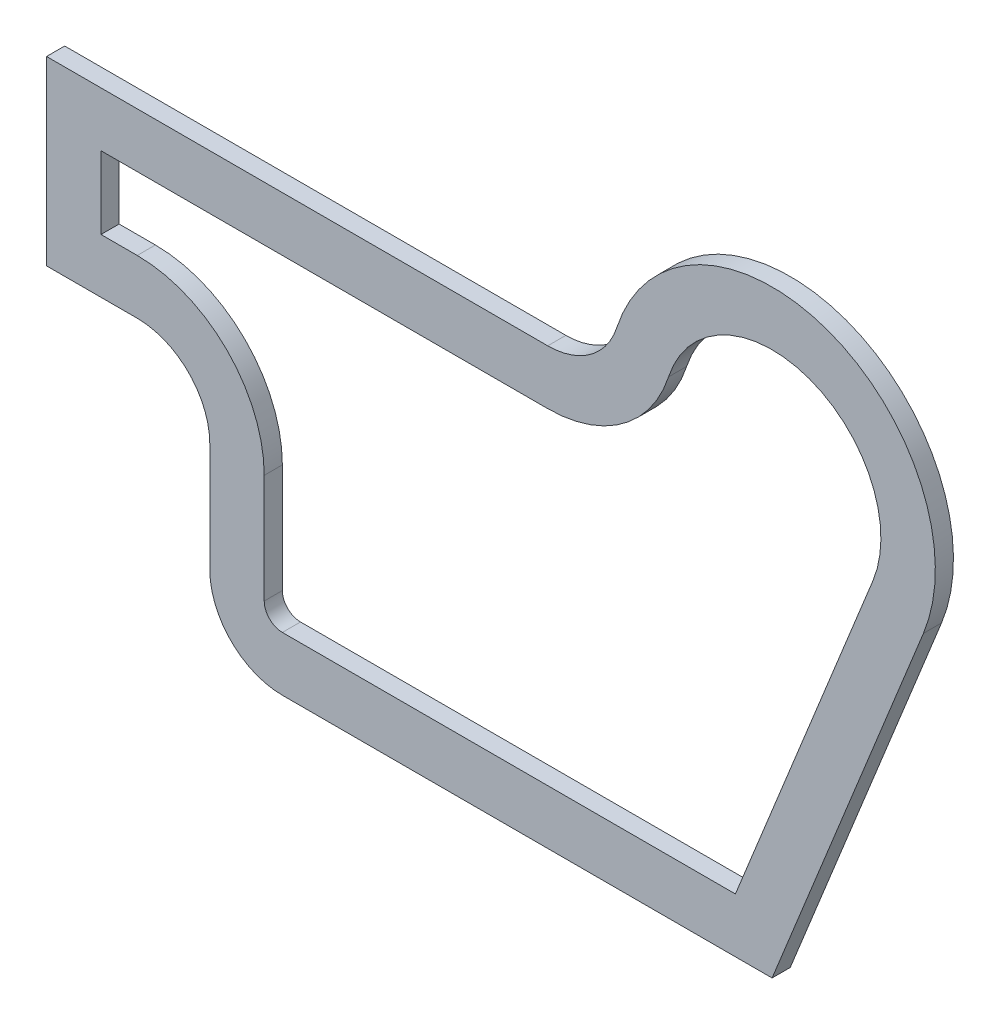
from build123d import *

# Parameters (mm, degrees)
SKETCH1_R           = 20
BOSS_EXTRUDE1_DEPTH = 5
CUT_EXTRUDE1_DEPTH  = 6


with BuildPart() as part:
    # Sketch1 → Boss-Extrude1 (new body)
    with BuildSketch(Plane.XY):
        with BuildLine():
            Line((-135, -120), (0, -120))
            Line((0, -120), (0, -45))
            ThreePointArc((0, -45), (-31.819805153, -31.819805153), (-45, 0))
            Line((-45, 0), (-61.846584492, 0))
            Line((-61.846584492, 0), (-200, 0))
            Line((-200, 0), (-200, -50))
            Line((-200, -50), (-175, -50))
            Line((-175, -50), (-155, -50))
            Line((-155, -50), (-155, -70))
            Line((-155, -70), (-155, -100))
            ThreePointArc((-155, -100), (-135, -80), (-115, -100))
            ThreePointArc((-115, -100), (-120.857864376, -114.142135624), (-135, -120))
        make_face()
        with BuildLine():
            ThreePointArc((-45, 0), (-44.450866059, 7.008602326), (-42.816866375, 13.846153034))
            ThreePointArc((-42.816866375, 13.846153034), (-50.079616665, 3.827848916), (-61.846584492, 0))
            Line((-61.846584492, 0), (-45, 0))
        make_face()
        with Locations((-135, -100)):
            Circle(SKETCH1_R)
        with BuildLine():
            ThreePointArc((-175, -50), (-160.857864376, -55.857864376), (-155, -70))
            Line((-155, -70), (-155, -50))
            Line((-155, -50), (-175, -50))
        make_face()
        with BuildLine():
            Line((0, -120), (41.71611649, -16.875))
            ThreePointArc((41.71611649, -16.875), (25.155764747, -37.312028891), (0, -45))
            Line((0, -45), (0, -120))
        make_face()
        with BuildLine():
            ThreePointArc((0, -45), (25.155764747, -37.312028891), (41.71611649, -16.875))
            ThreePointArc((41.71611649, -16.875), (44.171400487, -8.595776811), (45, 0))
            ThreePointArc((45, 0), (7.008602326, 44.450866059), (-42.816866375, 13.846153034))
            ThreePointArc((-42.816866375, 13.846153034), (-44.450866059, 7.008602326), (-45, 0))
            Line((-45, 0), (0, 0))
            Line((0, 0), (0, -45))
        make_face()
        with BuildLine():
            ThreePointArc((-45, 0), (-31.819805153, -31.819805153), (0, -45))
            Line((0, -45), (0, 0))
            Line((0, 0), (-45, 0))
        make_face()
    extrude(amount=BOSS_EXTRUDE1_DEPTH)

    # Sketch2 → Cut-Extrude1 (cut, through all)
    with BuildSketch(Plane.XY.offset(5)):
        with BuildLine():
            Line((-61.846584384, -15), (-185, -15))
            Line((-185, -15), (-185, -35))
            Line((-185, -35), (-175, -35))
            ThreePointArc((-175, -35), (-150.251262658, -45.251262658), (-140, -70))
            Line((-140, -70), (-140, -100))
            ThreePointArc((-140, -100), (-138.535533906, -103.535533906), (-135, -105))
            Line((-135, -105), (-10.112997937, -105))
            Line((-10.112997937, -105), (27.810744327, -11.25))
            ThreePointArc((27.810744327, -11.25), (10.246955881, 28.195742501), (-28.544577408, 9.230769231))
            ThreePointArc((-28.544577408, 9.230769231), (-41.254390195, -8.301263902), (-61.846584384, -15))
        make_face()
    extrude(amount=-CUT_EXTRUDE1_DEPTH, mode=Mode.SUBTRACT)


solid = part.part
